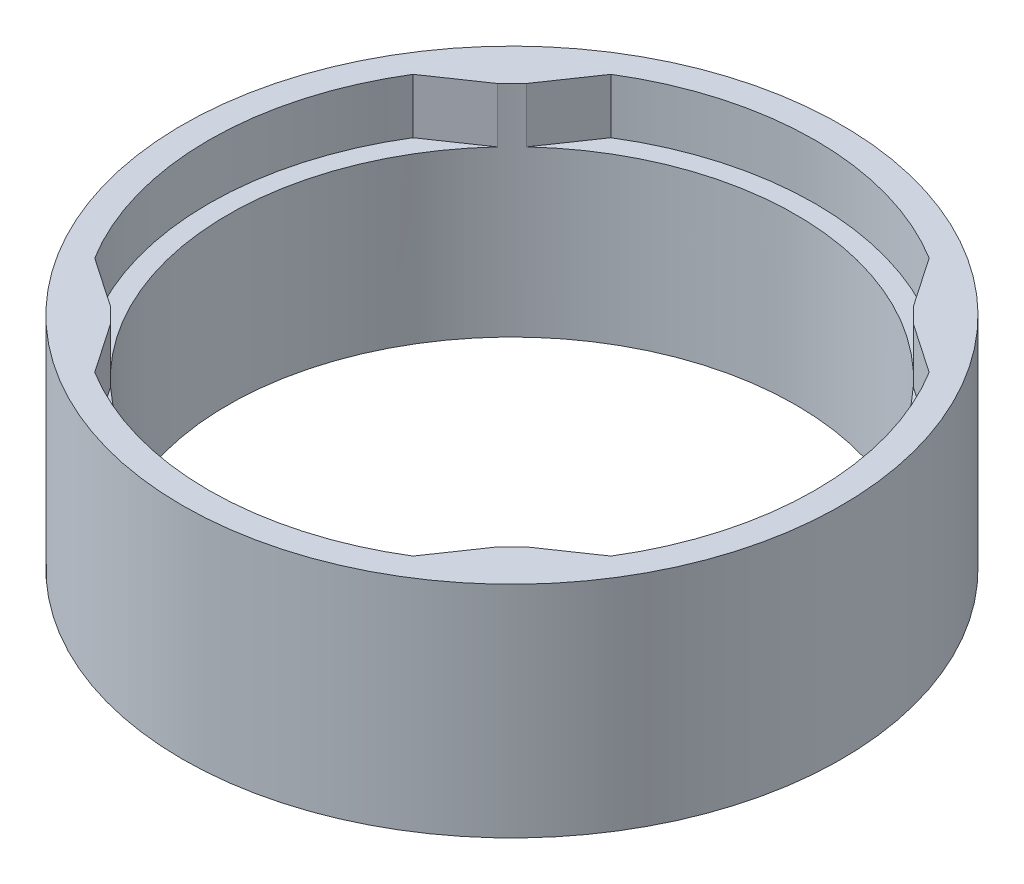
from build123d import *

# Parameters (mm, degrees)
SKETCH1_R           = 76.2
SKETCH1_R_2         = 65.659
BOSS_EXTRUDE1_DEPTH = 50.8
CUT_EXTRUDE1_DEPTH  = 12.7
CIRPATTERN1_COUNT   = 4


with BuildPart() as part:
    # Sketch1 → Boss-Extrude1 (new body)
    with BuildSketch(Plane(origin=(0, 0, 0), x_dir=(1, 0, 0), z_dir=(0, 1, 0))):
        Circle(SKETCH1_R)
        Circle(SKETCH1_R_2, mode=Mode.SUBTRACT)
    extrude(amount=-BOSS_EXTRUDE1_DEPTH)

    # Sketch2 → Cut-Extrude1 (cut)
    with BuildSketch(Plane(origin=(0, 0, 0), x_dir=(1, 0, 0), z_dir=(0, 1, 0))):
        with BuildLine():
            Line((-48.080896893, -44.713886377), (-59.672253185, -36.793926344))
            ThreePointArc((-59.672253185, -36.793926344), (-70.104, 0), (-59.672253185, 36.793926344))
            Line((-59.672253185, 36.793926344), (-48.080896893, 44.713886377))
            ThreePointArc((-48.080896893, 44.713886377), (-65.659, 0), (-48.080896893, -44.713886377))
        make_face()
    cut_extrude1 = extrude(amount=-CUT_EXTRUDE1_DEPTH, mode=Mode.SUBTRACT)

    # CirPattern1: Cut-Extrude1 ×4 about axis
    cirpattern1_axis = Axis((0, 0, 0), (0, 1, 0))
    for i in range(1, CIRPATTERN1_COUNT):
        add(cut_extrude1.rotate(cirpattern1_axis, i * 360 / CIRPATTERN1_COUNT), mode=Mode.SUBTRACT)


solid = part.part
